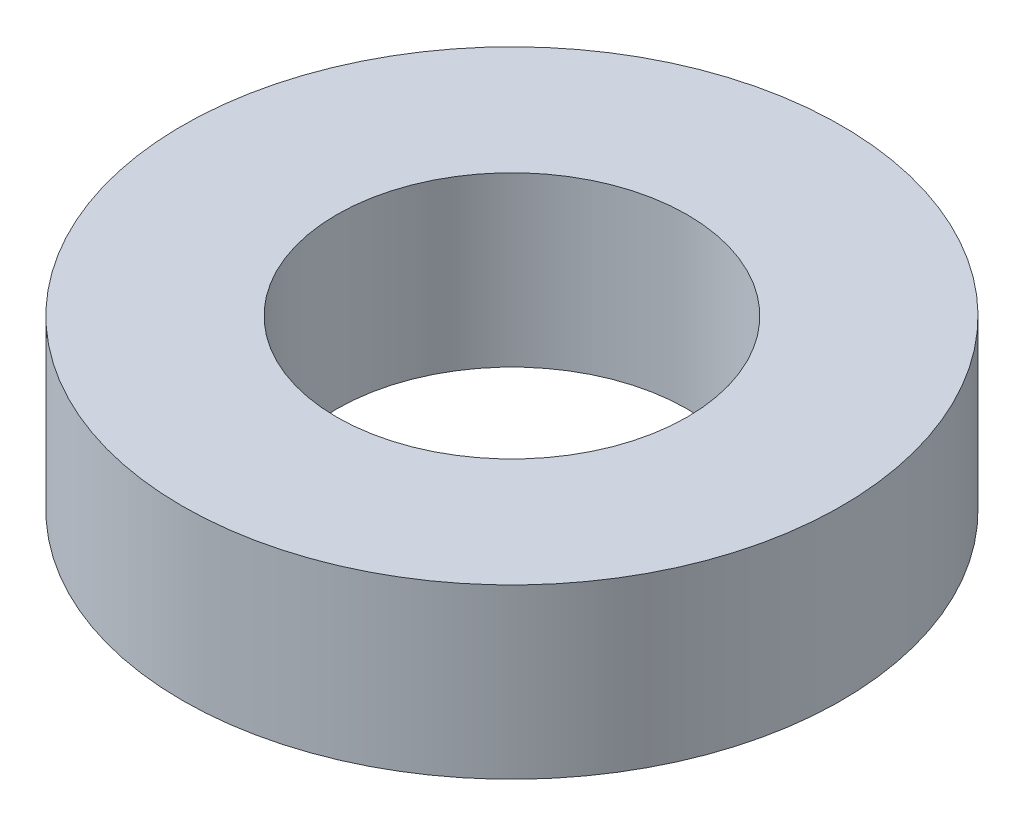
from build123d import *

# Parameters (mm, degrees)
SKETCH1_R           = 23.5
SKETCH1_R_2         = 12.5
BOSS_EXTRUDE1_DEPTH = 12


with BuildPart() as part:
    # Sketch1 → Boss-Extrude1 (new body)
    with BuildSketch(Plane(origin=(0, 0, 0), x_dir=(1, 0, 0), z_dir=(0, 1, 0))):
        Circle(SKETCH1_R)
        Circle(SKETCH1_R_2, mode=Mode.SUBTRACT)
    extrude(amount=BOSS_EXTRUDE1_DEPTH)


solid = part.part
